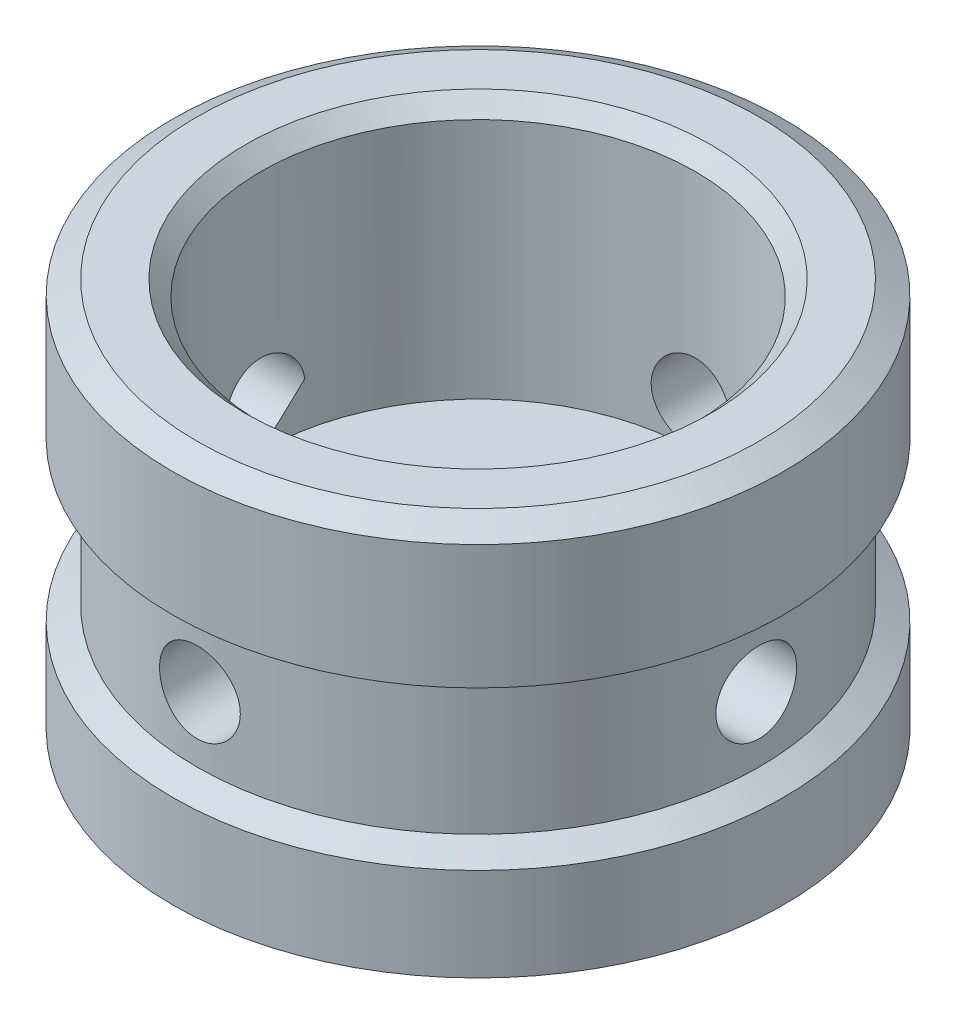
from build123d import *

# Parameters (mm, degrees)
SKETCH2_R          = 1.651
CUT_EXTRUDE1_DEPTH = 11.5
CIRPATTERN1_COUNT  = 4
SKETCH3_R          = 8.89
CUT_EXTRUDE3_DEPTH = 10.541
SKETCH4_R          = 8.89
CUT_EXTRUDE4_DEPTH = 1.27
CHAMFER1_SIZE      = 0.635


with BuildPart() as part:
    # Sketch1 → Revolve1 (revolve)
    with BuildSketch(Plane.XY):
        Polygon((11.5, -7.62), (12.497460133, -7.044116124), (12.497460133, -3.234116124), (11.5, -2.658232247), (11.5, 2.658232247), (12.497460133, 3.234116124), (12.497460133, 8.314116124), (11.5, 8.89), (0, 8.89), (0, -8.89), (9.5, -8.89), (9.5, -7.62), align=None)
    revolve(axis=Axis((0, 8.89, 0), (0, -1, 0)))

    # Sketch2 → Cut-Extrude1 (cut)
    with BuildSketch(Plane(origin=(0, 0, 0), x_dir=(0, 0, -1), z_dir=(1, 0, 0))):
        Circle(SKETCH2_R)
    cut_extrude1 = extrude(amount=-CUT_EXTRUDE1_DEPTH, mode=Mode.SUBTRACT)

    # CirPattern1: Cut-Extrude1 ×4 about axis
    cirpattern1_axis = Axis((0, 8.89, 0), (0, 1, 0))
    for i in range(1, CIRPATTERN1_COUNT):
        add(cut_extrude1.rotate(cirpattern1_axis, i * 360 / CIRPATTERN1_COUNT), mode=Mode.SUBTRACT)

    # Sketch3 → Cut-Extrude3 (cut)
    with BuildSketch(Plane(origin=(0, 8.89, 0), x_dir=(1, 0, 0), z_dir=(0, 1, 0))):
        Circle(SKETCH3_R)
    extrude(amount=-CUT_EXTRUDE3_DEPTH, mode=Mode.SUBTRACT)

    # Sketch4 → Cut-Extrude4 (cut)
    with BuildSketch(Plane.XZ.offset(8.89)):
        Circle(SKETCH4_R)
    extrude(amount=-CUT_EXTRUDE4_DEPTH, mode=Mode.SUBTRACT)

    # Chamfer1
    chamfer1_edges = [part.edges().sort_by_distance(p)[0] for p in [
        (-8.89, 8.89, 0),
    ]]
    chamfer(chamfer1_edges, length=CHAMFER1_SIZE)


solid = part.part
